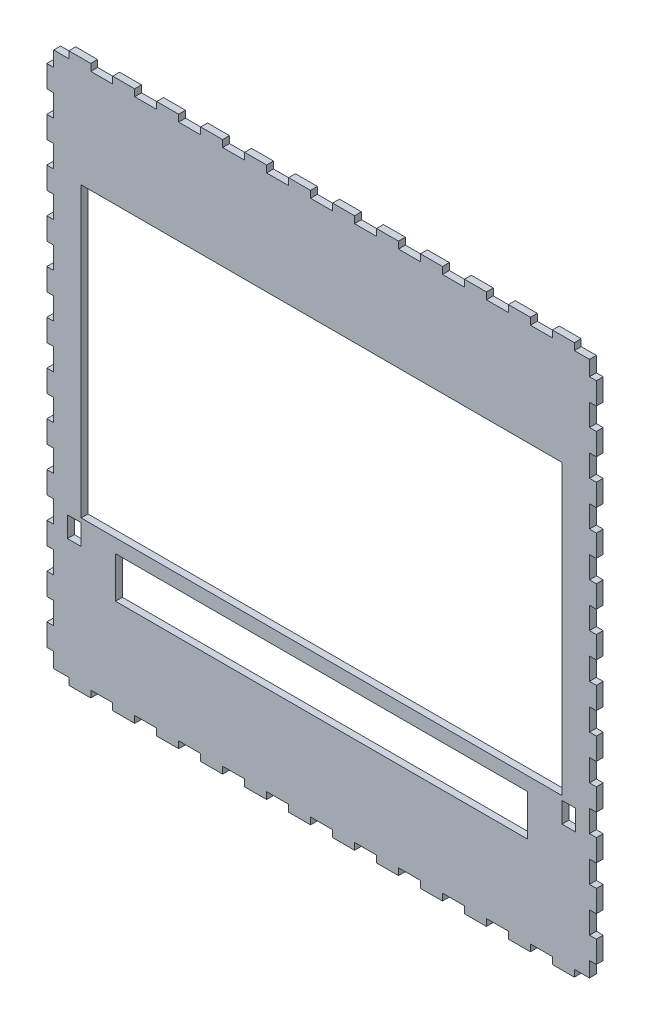
from build123d import *

# Parameters (mm, degrees)
ESQUISSE1_W                = 400
ESQUISSE1_H                = 400
ESQUISSE1_W_2              = 350
ESQUISSE1_H_2              = 210
ESQUISSE1_W_3              = 300
ESQUISSE1_H_3              = 30
BOSS_EXTRU_1_DEPTH         = 5
ESQUISSE2_W                = 16
ESQUISSE2_H                = 5
ENL_V_MAT_EXTRU_1_DEPTH    = 5
R_P_TITION_LIN_AIRE1_COUNT = 13
R_P_TITION_LIN_AIRE1_PITCH = 32
SYM_TRIE1_COPY_1_SKETCH_W  = 16
SYM_TRIE1_COPY_1_SKETCH_H  = 5
SYM_TRIE1_COPY_1_DEPTH     = 5
SYM_TRIE1_COPY_2_SKETCH_W  = 16
SYM_TRIE1_COPY_2_SKETCH_H  = 5
SYM_TRIE1_COPY_2_DEPTH     = 5
SYM_TRIE1_COPY_3_SKETCH_W  = 16
SYM_TRIE1_COPY_3_SKETCH_H  = 5
SYM_TRIE1_COPY_3_DEPTH     = 5
SYM_TRIE1_COPY_4_SKETCH_W  = 16
SYM_TRIE1_COPY_4_SKETCH_H  = 5
SYM_TRIE1_COPY_4_DEPTH     = 5
SYM_TRIE1_COPY_5_SKETCH_W  = 16
SYM_TRIE1_COPY_5_SKETCH_H  = 5
SYM_TRIE1_COPY_5_DEPTH     = 5
SYM_TRIE1_COPY_6_SKETCH_W  = 16
SYM_TRIE1_COPY_6_SKETCH_H  = 5
SYM_TRIE1_COPY_6_DEPTH     = 5
SYM_TRIE1_COPY_7_SKETCH_W  = 16
SYM_TRIE1_COPY_7_SKETCH_H  = 5
SYM_TRIE1_COPY_7_DEPTH     = 5
SYM_TRIE1_COPY_8_SKETCH_W  = 16
SYM_TRIE1_COPY_8_SKETCH_H  = 5
SYM_TRIE1_COPY_8_DEPTH     = 5
SYM_TRIE1_COPY_9_SKETCH_W  = 16
SYM_TRIE1_COPY_9_SKETCH_H  = 5
SYM_TRIE1_COPY_9_DEPTH     = 5
SYM_TRIE1_COPY_10_SKETCH_W = 16
SYM_TRIE1_COPY_10_SKETCH_H = 5
SYM_TRIE1_COPY_10_DEPTH    = 5
SYM_TRIE1_COPY_11_SKETCH_W = 16
SYM_TRIE1_COPY_11_SKETCH_H = 5
SYM_TRIE1_COPY_11_DEPTH    = 5
SYM_TRIE1_COPY_12_SKETCH_W = 16
SYM_TRIE1_COPY_12_SKETCH_H = 5
SYM_TRIE1_COPY_12_DEPTH    = 5
ESQUISSE3_W                = 5
ESQUISSE3_H                = 16
ENL_V_MAT_EXTRU_2_DEPTH    = 10
R_P_TITION_LIN_AIRE2_COUNT = 13
R_P_TITION_LIN_AIRE2_PITCH = 32
SYM_TRIE2_COPY_1_SKETCH_W  = 5
SYM_TRIE2_COPY_1_SKETCH_H  = 16
SYM_TRIE2_COPY_1_DEPTH     = 10
SYM_TRIE2_COPY_2_SKETCH_W  = 5
SYM_TRIE2_COPY_2_SKETCH_H  = 16
SYM_TRIE2_COPY_2_DEPTH     = 10
SYM_TRIE2_COPY_3_SKETCH_W  = 5
SYM_TRIE2_COPY_3_SKETCH_H  = 16
SYM_TRIE2_COPY_3_DEPTH     = 10
SYM_TRIE2_COPY_4_SKETCH_W  = 5
SYM_TRIE2_COPY_4_SKETCH_H  = 16
SYM_TRIE2_COPY_4_DEPTH     = 10
SYM_TRIE2_COPY_5_SKETCH_W  = 5
SYM_TRIE2_COPY_5_SKETCH_H  = 16
SYM_TRIE2_COPY_5_DEPTH     = 10
SYM_TRIE2_COPY_6_SKETCH_W  = 5
SYM_TRIE2_COPY_6_SKETCH_H  = 16
SYM_TRIE2_COPY_6_DEPTH     = 10
SYM_TRIE2_COPY_7_SKETCH_W  = 5
SYM_TRIE2_COPY_7_SKETCH_H  = 16
SYM_TRIE2_COPY_7_DEPTH     = 10
SYM_TRIE2_COPY_8_SKETCH_W  = 5
SYM_TRIE2_COPY_8_SKETCH_H  = 16
SYM_TRIE2_COPY_8_DEPTH     = 10
SYM_TRIE2_COPY_9_SKETCH_W  = 5
SYM_TRIE2_COPY_9_SKETCH_H  = 16
SYM_TRIE2_COPY_9_DEPTH     = 10
SYM_TRIE2_COPY_10_SKETCH_W = 5
SYM_TRIE2_COPY_10_SKETCH_H = 16
SYM_TRIE2_COPY_10_DEPTH    = 10
SYM_TRIE2_COPY_11_SKETCH_W = 5
SYM_TRIE2_COPY_11_SKETCH_H = 16
SYM_TRIE2_COPY_11_DEPTH    = 10
SYM_TRIE2_COPY_12_SKETCH_W = 5
SYM_TRIE2_COPY_12_SKETCH_H = 16
SYM_TRIE2_COPY_12_DEPTH    = 10
ESQUISSE4_W                = 10
ESQUISSE4_H                = 15
ENL_V_MAT_EXTRU_3_DEPTH    = 5


with BuildPart() as part:
    # Esquisse1 → Boss.-Extru.1 (new body)
    with BuildSketch(Plane.XY):
        with Locations((200, -200)):
            Rectangle(ESQUISSE1_W, ESQUISSE1_H)
        with Locations((200, -185)):
            Rectangle(ESQUISSE1_W_2, ESQUISSE1_H_2, mode=Mode.SUBTRACT)
        with Locations((200, -315)):
            Rectangle(ESQUISSE1_W_3, ESQUISSE1_H_3, mode=Mode.SUBTRACT)
    extrude(amount=BOSS_EXTRU_1_DEPTH)

    # Esquisse2 → Enlèv. mat.-Extru.1 (cut)
    with BuildSketch(Plane.XY.offset(5)):
        with Locations((8, -397.5)):
            Rectangle(ESQUISSE2_W, ESQUISSE2_H)
    enl_v_mat_extru_1 = extrude(amount=-ENL_V_MAT_EXTRU_1_DEPTH, mode=Mode.SUBTRACT)

    # Répétition linéaire1: Enlèv. mat.-Extru.1 ×13
    with Locations(*[(i * R_P_TITION_LIN_AIRE1_PITCH, 0, 0) for i in range(1, R_P_TITION_LIN_AIRE1_COUNT)]):
        add(enl_v_mat_extru_1, mode=Mode.SUBTRACT)

    # Symétrie1: Enlèv. mat.-Extru.1 across plane
    add(enl_v_mat_extru_1.mirror(Plane(origin=(0, -200, 0), x_dir=(0, 0, 1), z_dir=(0, -1, 0))), mode=Mode.SUBTRACT)

    # Symétrie1 copy 1 sketch → Symétrie1 copy 1 (cut)
    with BuildSketch(Plane(origin=(32, -400, 5), x_dir=(1, 0, 0), z_dir=(0, 0, 1))):
        with Locations((8, 397.5)):
            Rectangle(SYM_TRIE1_COPY_1_SKETCH_W, SYM_TRIE1_COPY_1_SKETCH_H)
    extrude(amount=-SYM_TRIE1_COPY_1_DEPTH, mode=Mode.SUBTRACT)

    # Symétrie1 copy 2 sketch → Symétrie1 copy 2 (cut)
    with BuildSketch(Plane(origin=(64, -400, 5), x_dir=(1, 0, 0), z_dir=(0, 0, 1))):
        with Locations((8, 397.5)):
            Rectangle(SYM_TRIE1_COPY_2_SKETCH_W, SYM_TRIE1_COPY_2_SKETCH_H)
    extrude(amount=-SYM_TRIE1_COPY_2_DEPTH, mode=Mode.SUBTRACT)

    # Symétrie1 copy 3 sketch → Symétrie1 copy 3 (cut)
    with BuildSketch(Plane(origin=(96, -400, 5), x_dir=(1, 0, 0), z_dir=(0, 0, 1))):
        with Locations((8, 397.5)):
            Rectangle(SYM_TRIE1_COPY_3_SKETCH_W, SYM_TRIE1_COPY_3_SKETCH_H)
    extrude(amount=-SYM_TRIE1_COPY_3_DEPTH, mode=Mode.SUBTRACT)

    # Symétrie1 copy 4 sketch → Symétrie1 copy 4 (cut)
    with BuildSketch(Plane(origin=(128, -400, 5), x_dir=(1, 0, 0), z_dir=(0, 0, 1))):
        with Locations((8, 397.5)):
            Rectangle(SYM_TRIE1_COPY_4_SKETCH_W, SYM_TRIE1_COPY_4_SKETCH_H)
    extrude(amount=-SYM_TRIE1_COPY_4_DEPTH, mode=Mode.SUBTRACT)

    # Symétrie1 copy 5 sketch → Symétrie1 copy 5 (cut)
    with BuildSketch(Plane(origin=(160, -400, 5), x_dir=(1, 0, 0), z_dir=(0, 0, 1))):
        with Locations((8, 397.5)):
            Rectangle(SYM_TRIE1_COPY_5_SKETCH_W, SYM_TRIE1_COPY_5_SKETCH_H)
    extrude(amount=-SYM_TRIE1_COPY_5_DEPTH, mode=Mode.SUBTRACT)

    # Symétrie1 copy 6 sketch → Symétrie1 copy 6 (cut)
    with BuildSketch(Plane(origin=(192, -400, 5), x_dir=(1, 0, 0), z_dir=(0, 0, 1))):
        with Locations((8, 397.5)):
            Rectangle(SYM_TRIE1_COPY_6_SKETCH_W, SYM_TRIE1_COPY_6_SKETCH_H)
    extrude(amount=-SYM_TRIE1_COPY_6_DEPTH, mode=Mode.SUBTRACT)

    # Symétrie1 copy 7 sketch → Symétrie1 copy 7 (cut)
    with BuildSketch(Plane(origin=(224, -400, 5), x_dir=(1, 0, 0), z_dir=(0, 0, 1))):
        with Locations((8, 397.5)):
            Rectangle(SYM_TRIE1_COPY_7_SKETCH_W, SYM_TRIE1_COPY_7_SKETCH_H)
    extrude(amount=-SYM_TRIE1_COPY_7_DEPTH, mode=Mode.SUBTRACT)

    # Symétrie1 copy 8 sketch → Symétrie1 copy 8 (cut)
    with BuildSketch(Plane(origin=(256, -400, 5), x_dir=(1, 0, 0), z_dir=(0, 0, 1))):
        with Locations((8, 397.5)):
            Rectangle(SYM_TRIE1_COPY_8_SKETCH_W, SYM_TRIE1_COPY_8_SKETCH_H)
    extrude(amount=-SYM_TRIE1_COPY_8_DEPTH, mode=Mode.SUBTRACT)

    # Symétrie1 copy 9 sketch → Symétrie1 copy 9 (cut)
    with BuildSketch(Plane(origin=(288, -400, 5), x_dir=(1, 0, 0), z_dir=(0, 0, 1))):
        with Locations((8, 397.5)):
            Rectangle(SYM_TRIE1_COPY_9_SKETCH_W, SYM_TRIE1_COPY_9_SKETCH_H)
    extrude(amount=-SYM_TRIE1_COPY_9_DEPTH, mode=Mode.SUBTRACT)

    # Symétrie1 copy 10 sketch → Symétrie1 copy 10 (cut)
    with BuildSketch(Plane(origin=(320, -400, 5), x_dir=(1, 0, 0), z_dir=(0, 0, 1))):
        with Locations((8, 397.5)):
            Rectangle(SYM_TRIE1_COPY_10_SKETCH_W, SYM_TRIE1_COPY_10_SKETCH_H)
    extrude(amount=-SYM_TRIE1_COPY_10_DEPTH, mode=Mode.SUBTRACT)

    # Symétrie1 copy 11 sketch → Symétrie1 copy 11 (cut)
    with BuildSketch(Plane(origin=(352, -400, 5), x_dir=(1, 0, 0), z_dir=(0, 0, 1))):
        with Locations((8, 397.5)):
            Rectangle(SYM_TRIE1_COPY_11_SKETCH_W, SYM_TRIE1_COPY_11_SKETCH_H)
    extrude(amount=-SYM_TRIE1_COPY_11_DEPTH, mode=Mode.SUBTRACT)

    # Symétrie1 copy 12 sketch → Symétrie1 copy 12 (cut)
    with BuildSketch(Plane(origin=(384, -400, 5), x_dir=(1, 0, 0), z_dir=(0, 0, 1))):
        with Locations((8, 397.5)):
            Rectangle(SYM_TRIE1_COPY_12_SKETCH_W, SYM_TRIE1_COPY_12_SKETCH_H)
    extrude(amount=-SYM_TRIE1_COPY_12_DEPTH, mode=Mode.SUBTRACT)

    # Esquisse3 → Enlèv. mat.-Extru.2 (cut)
    with BuildSketch(Plane.XY.offset(5)):
        with Locations((2.5, -392)):
            Rectangle(ESQUISSE3_W, ESQUISSE3_H)
    enl_v_mat_extru_2 = extrude(amount=-ENL_V_MAT_EXTRU_2_DEPTH, mode=Mode.SUBTRACT)

    # Répétition linéaire2: Enlèv. mat.-Extru.2 ×13
    with Locations(*[(0, i * R_P_TITION_LIN_AIRE2_PITCH, 0) for i in range(1, R_P_TITION_LIN_AIRE2_COUNT)]):
        add(enl_v_mat_extru_2, mode=Mode.SUBTRACT)

    # Symétrie2: Enlèv. mat.-Extru.2 across plane
    add(enl_v_mat_extru_2.mirror(Plane.ZY.offset(-200)), mode=Mode.SUBTRACT)

    # Symétrie2 copy 1 sketch → Symétrie2 copy 1 (cut)
    with BuildSketch(Plane(origin=(400, 32, 5), x_dir=(-1, 0, 0), z_dir=(0, 0, 1))):
        with Locations((2.5, 392)):
            Rectangle(SYM_TRIE2_COPY_1_SKETCH_W, SYM_TRIE2_COPY_1_SKETCH_H)
    extrude(amount=-SYM_TRIE2_COPY_1_DEPTH, mode=Mode.SUBTRACT)

    # Symétrie2 copy 2 sketch → Symétrie2 copy 2 (cut)
    with BuildSketch(Plane(origin=(400, 64, 5), x_dir=(-1, 0, 0), z_dir=(0, 0, 1))):
        with Locations((2.5, 392)):
            Rectangle(SYM_TRIE2_COPY_2_SKETCH_W, SYM_TRIE2_COPY_2_SKETCH_H)
    extrude(amount=-SYM_TRIE2_COPY_2_DEPTH, mode=Mode.SUBTRACT)

    # Symétrie2 copy 3 sketch → Symétrie2 copy 3 (cut)
    with BuildSketch(Plane(origin=(400, 96, 5), x_dir=(-1, 0, 0), z_dir=(0, 0, 1))):
        with Locations((2.5, 392)):
            Rectangle(SYM_TRIE2_COPY_3_SKETCH_W, SYM_TRIE2_COPY_3_SKETCH_H)
    extrude(amount=-SYM_TRIE2_COPY_3_DEPTH, mode=Mode.SUBTRACT)

    # Symétrie2 copy 4 sketch → Symétrie2 copy 4 (cut)
    with BuildSketch(Plane(origin=(400, 128, 5), x_dir=(-1, 0, 0), z_dir=(0, 0, 1))):
        with Locations((2.5, 392)):
            Rectangle(SYM_TRIE2_COPY_4_SKETCH_W, SYM_TRIE2_COPY_4_SKETCH_H)
    extrude(amount=-SYM_TRIE2_COPY_4_DEPTH, mode=Mode.SUBTRACT)

    # Symétrie2 copy 5 sketch → Symétrie2 copy 5 (cut)
    with BuildSketch(Plane(origin=(400, 160, 5), x_dir=(-1, 0, 0), z_dir=(0, 0, 1))):
        with Locations((2.5, 392)):
            Rectangle(SYM_TRIE2_COPY_5_SKETCH_W, SYM_TRIE2_COPY_5_SKETCH_H)
    extrude(amount=-SYM_TRIE2_COPY_5_DEPTH, mode=Mode.SUBTRACT)

    # Symétrie2 copy 6 sketch → Symétrie2 copy 6 (cut)
    with BuildSketch(Plane(origin=(400, 192, 5), x_dir=(-1, 0, 0), z_dir=(0, 0, 1))):
        with Locations((2.5, 392)):
            Rectangle(SYM_TRIE2_COPY_6_SKETCH_W, SYM_TRIE2_COPY_6_SKETCH_H)
    extrude(amount=-SYM_TRIE2_COPY_6_DEPTH, mode=Mode.SUBTRACT)

    # Symétrie2 copy 7 sketch → Symétrie2 copy 7 (cut)
    with BuildSketch(Plane(origin=(400, 224, 5), x_dir=(-1, 0, 0), z_dir=(0, 0, 1))):
        with Locations((2.5, 392)):
            Rectangle(SYM_TRIE2_COPY_7_SKETCH_W, SYM_TRIE2_COPY_7_SKETCH_H)
    extrude(amount=-SYM_TRIE2_COPY_7_DEPTH, mode=Mode.SUBTRACT)

    # Symétrie2 copy 8 sketch → Symétrie2 copy 8 (cut)
    with BuildSketch(Plane(origin=(400, 256, 5), x_dir=(-1, 0, 0), z_dir=(0, 0, 1))):
        with Locations((2.5, 392)):
            Rectangle(SYM_TRIE2_COPY_8_SKETCH_W, SYM_TRIE2_COPY_8_SKETCH_H)
    extrude(amount=-SYM_TRIE2_COPY_8_DEPTH, mode=Mode.SUBTRACT)

    # Symétrie2 copy 9 sketch → Symétrie2 copy 9 (cut)
    with BuildSketch(Plane(origin=(400, 288, 5), x_dir=(-1, 0, 0), z_dir=(0, 0, 1))):
        with Locations((2.5, 392)):
            Rectangle(SYM_TRIE2_COPY_9_SKETCH_W, SYM_TRIE2_COPY_9_SKETCH_H)
    extrude(amount=-SYM_TRIE2_COPY_9_DEPTH, mode=Mode.SUBTRACT)

    # Symétrie2 copy 10 sketch → Symétrie2 copy 10 (cut)
    with BuildSketch(Plane(origin=(400, 320, 5), x_dir=(-1, 0, 0), z_dir=(0, 0, 1))):
        with Locations((2.5, 392)):
            Rectangle(SYM_TRIE2_COPY_10_SKETCH_W, SYM_TRIE2_COPY_10_SKETCH_H)
    extrude(amount=-SYM_TRIE2_COPY_10_DEPTH, mode=Mode.SUBTRACT)

    # Symétrie2 copy 11 sketch → Symétrie2 copy 11 (cut)
    with BuildSketch(Plane(origin=(400, 352, 5), x_dir=(-1, 0, 0), z_dir=(0, 0, 1))):
        with Locations((2.5, 392)):
            Rectangle(SYM_TRIE2_COPY_11_SKETCH_W, SYM_TRIE2_COPY_11_SKETCH_H)
    extrude(amount=-SYM_TRIE2_COPY_11_DEPTH, mode=Mode.SUBTRACT)

    # Symétrie2 copy 12 sketch → Symétrie2 copy 12 (cut)
    with BuildSketch(Plane(origin=(400, 384, 5), x_dir=(-1, 0, 0), z_dir=(0, 0, 1))):
        with Locations((2.5, 392)):
            Rectangle(SYM_TRIE2_COPY_12_SKETCH_W, SYM_TRIE2_COPY_12_SKETCH_H)
    extrude(amount=-SYM_TRIE2_COPY_12_DEPTH, mode=Mode.SUBTRACT)

    # Esquisse4 → Enlèv. mat.-Extru.3 (cut)
    with BuildSketch(Plane.XY.offset(5)):
        with Locations((380, -300.5)):
            Rectangle(ESQUISSE4_W, ESQUISSE4_H)
    enl_v_mat_extru_3 = extrude(amount=-ENL_V_MAT_EXTRU_3_DEPTH, mode=Mode.SUBTRACT)

    # Symétrie3: Enlèv. mat.-Extru.3 across plane
    add(enl_v_mat_extru_3.mirror(Plane.ZY.offset(-200)), mode=Mode.SUBTRACT)


solid = part.part
